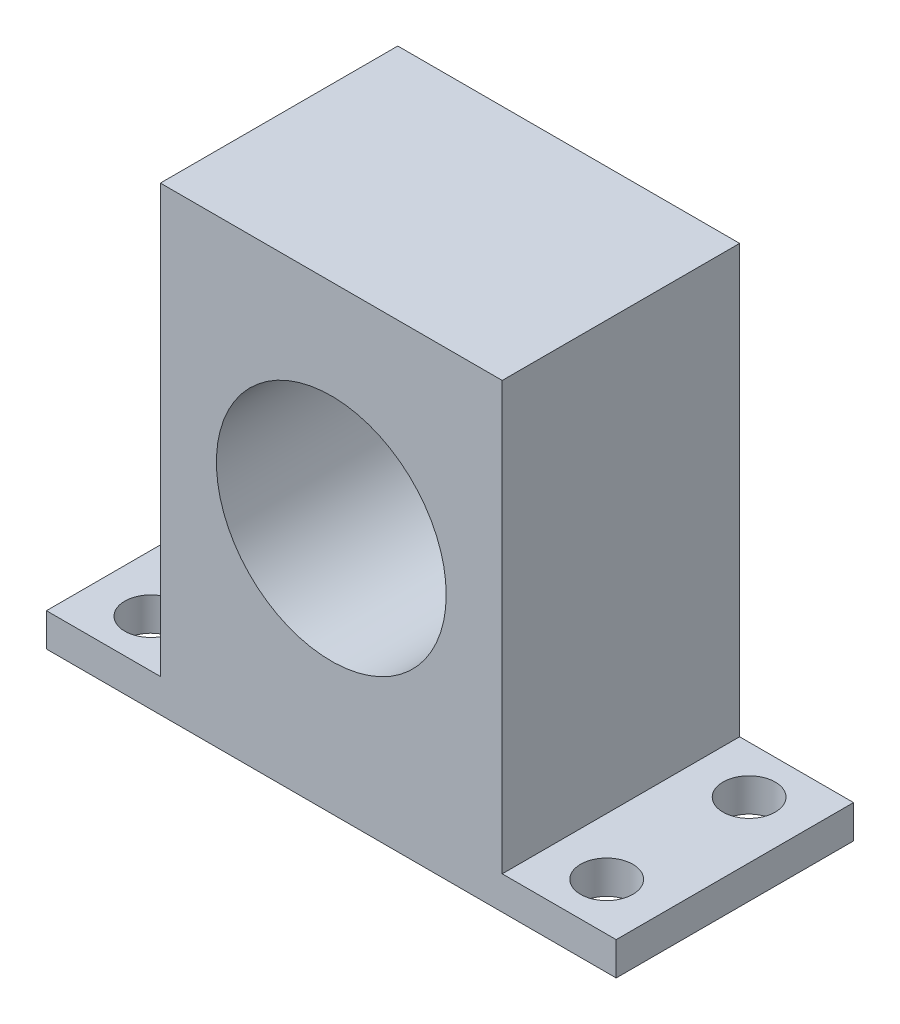
from build123d import *

# Parameters (mm, degrees)
SKETCH3_W           = 18
SKETCH3_H           = 22.5
BRACKETBASE_DEPTH   = 12.5
SKETCH4_R           = 6.05
HOLE_DEPTH          = 13.5
SKETCH5_W           = 30
SKETCH5_H           = 12.5
TABBASE_DEPTH       = 1.75
SKETCH6_R           = 1.375
MOUNTINGHOLES_DEPTH = 2.75


with BuildPart() as part:
    # Sketch3 → bracketBase (new body)
    with BuildSketch(Plane.XY):
        with Locations((9, 11.25)):
            Rectangle(SKETCH3_W, SKETCH3_H)
    extrude(amount=BRACKETBASE_DEPTH)

    # Sketch4 → hole (cut, through all)
    with BuildSketch(Plane.XY.offset(12.5)):
        with Locations((9, 11.25)):
            Circle(SKETCH4_R)
    extrude(amount=-HOLE_DEPTH, mode=Mode.SUBTRACT)

    # Sketch5 → tabBase (add)
    with BuildSketch(Plane.XZ):
        with Locations((9, 6.25)):
            Rectangle(SKETCH5_W, SKETCH5_H)
    extrude(amount=TABBASE_DEPTH)

    # Sketch6 → mountingHoles (cut, through all)
    with BuildSketch(Plane(origin=(0, 0, 0), x_dir=(1, 0, 0), z_dir=(0, 1, 0))):
        with Locations((-3, -2.5)):
            Circle(SKETCH6_R)
        with Locations((-3, -10)):
            Circle(SKETCH6_R)
        with Locations((21, -2.5)):
            Circle(SKETCH6_R)
        with Locations((21, -10)):
            Circle(SKETCH6_R)
    extrude(amount=-MOUNTINGHOLES_DEPTH, mode=Mode.SUBTRACT)


solid = part.part
